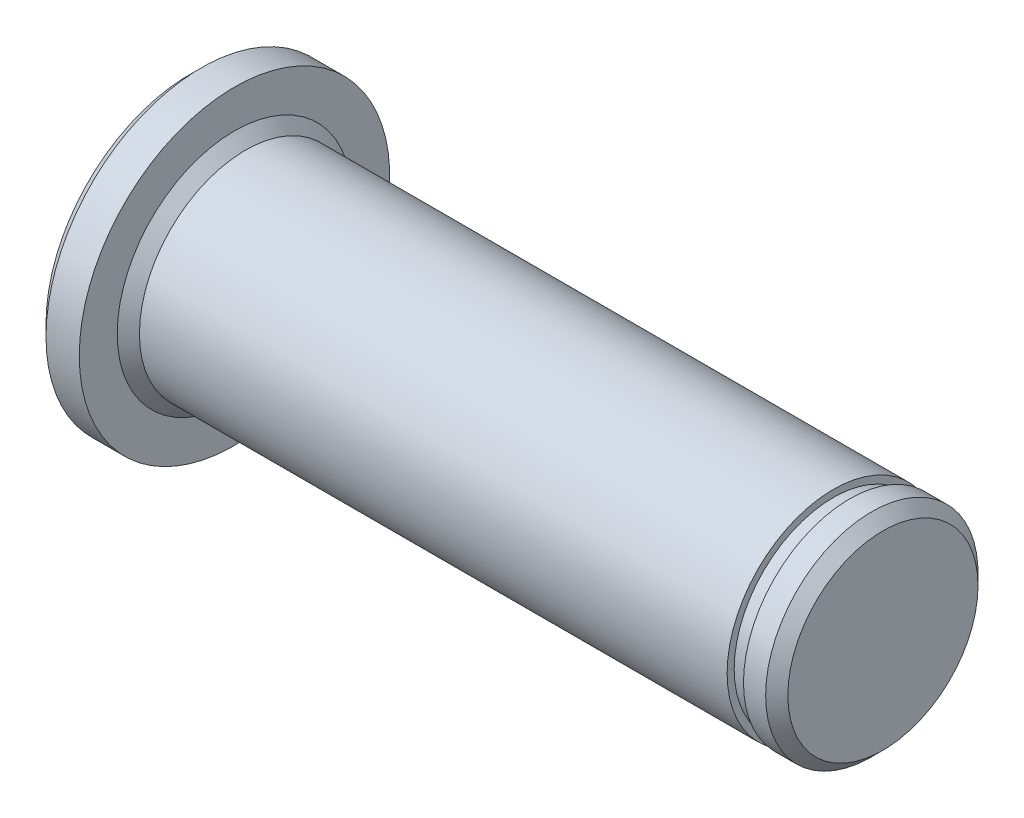
from build123d import *

# Parameters (mm, degrees)
CHAMFER1_SIZE = 0.5


with BuildPart() as part:
    # Sketch1 → Revolve1 (revolve)
    with BuildSketch(Plane.XY):
        Polygon((0, 4.7875), (0, 7), (-2, 7), (-2, 0), (29.237, 0), (29.237, 4.7875), (27.737, 4.7875), (27.737, 4.47), (27, 4.47), (27, 4.7875), align=None)
    revolve(axis=Axis((-78.535413295, 0, 0), (1, 0, 0)))

    # Chamfer1
    chamfer1_edges = [part.edges().sort_by_distance(p)[0] for p in [
        (0, -4.7875, 0),
        (-2, -7, 0),
        (29.237, -4.7875, 0),
    ]]
    chamfer(chamfer1_edges, length=CHAMFER1_SIZE)


solid = part.part
